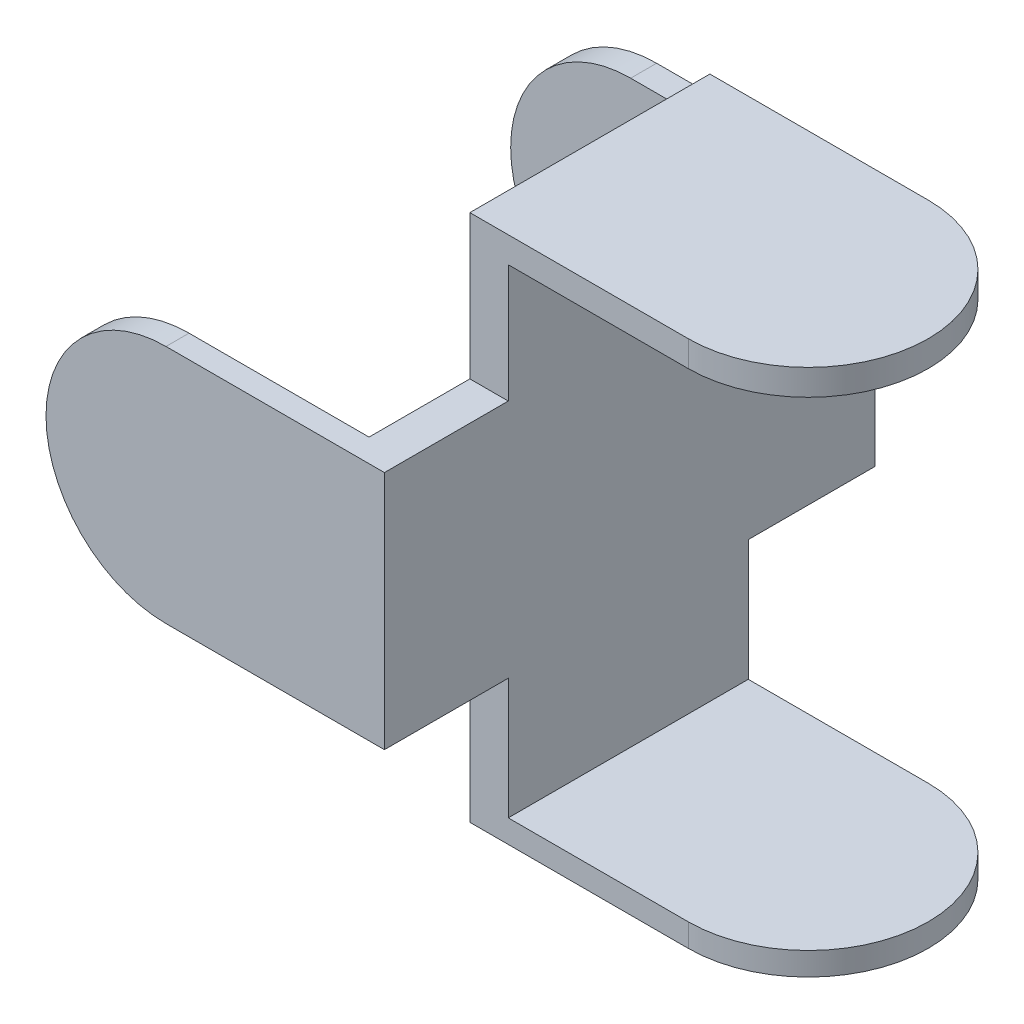
from build123d import *

# Parameters (mm, degrees)
EXTRUDE_5_DEPTH          = 25.4
EXTRUDE_5_DEPTH_BACK     = 25.7
CUT_EXTRUDE_1_DEPTH      = 23
CUT_EXTRUDE_1_DEPTH_BACK = 23
EXTRUDE_6_DEPTH          = 27.5
CUT_EXTRUDE_2_DEPTH      = 24.8
CUT_EXTRUDE_2_DEPTH_BACK = 25.1


with BuildPart() as part:
    # Эскиз5 → Бобышка-Вытянуть5 (new body, two sides)
    with BuildSketch(Plane.XY) as extrude_5_sk:
        with BuildLine():
            Line((0, 12.5), (22.75, 12.5))
            Line((22.75, 12.5), (22.75, -12.5))
            Line((22.75, -12.5), (0, -12.5))
            ThreePointArc((0, -12.5), (-12.5, 0), (0, 12.5))
        make_face()
    extrude(amount=EXTRUDE_5_DEPTH)
    extrude(extrude_5_sk.sketch, amount=-EXTRUDE_5_DEPTH_BACK)

    # Эскиз6 → Вырез-Вытянуть1 (cut, two sides)
    with BuildSketch(Plane.XY) as cut_extrude_1_sk:
        with BuildLine():
            Line((0, 12.5), (18.75, 12.5))
            Line((18.75, 12.5), (18.75, -12.5))
            Line((18.75, -12.5), (0, -12.5))
            ThreePointArc((0, -12.5), (-12.5, 0), (0, 12.5))
        make_face()
    extrude(amount=CUT_EXTRUDE_1_DEPTH, mode=Mode.SUBTRACT)
    extrude(cut_extrude_1_sk.sketch, amount=-CUT_EXTRUDE_1_DEPTH_BACK, mode=Mode.SUBTRACT)

    # Эскиз7 → Бобышка-Вытянуть6 (add, symmetric)
    with BuildSketch(Plane(origin=(0, 0, 0), x_dir=(1, 0, 0), z_dir=(0, 1, 0))):
        with BuildLine():
            Line((41.5, 12.5), (18.75, 12.5))
            Line((18.75, 12.5), (18.75, -12.5))
            Line((18.75, -12.5), (41.5, -12.5))
            ThreePointArc((41.5, -12.5), (54, 0), (41.5, 12.5))
        make_face()
    extrude(amount=EXTRUDE_6_DEPTH, both=True)

    # Эскиз8 → Вырез-Вытянуть2 (cut, two sides)
    with BuildSketch(Plane(origin=(0, 0, 0), x_dir=(1, 0, 0), z_dir=(0, 1, 0))) as cut_extrude_2_sk:
        with BuildLine():
            Line((41.5, 12.5), (22.75, 12.5))
            Line((22.75, 12.5), (22.75, -12.5))
            Line((22.75, -12.5), (41.5, -12.5))
            ThreePointArc((41.5, -12.5), (54, 0), (41.5, 12.5))
        make_face()
    extrude(amount=CUT_EXTRUDE_2_DEPTH, mode=Mode.SUBTRACT)
    extrude(cut_extrude_2_sk.sketch, amount=-CUT_EXTRUDE_2_DEPTH_BACK, mode=Mode.SUBTRACT)


solid = part.part
